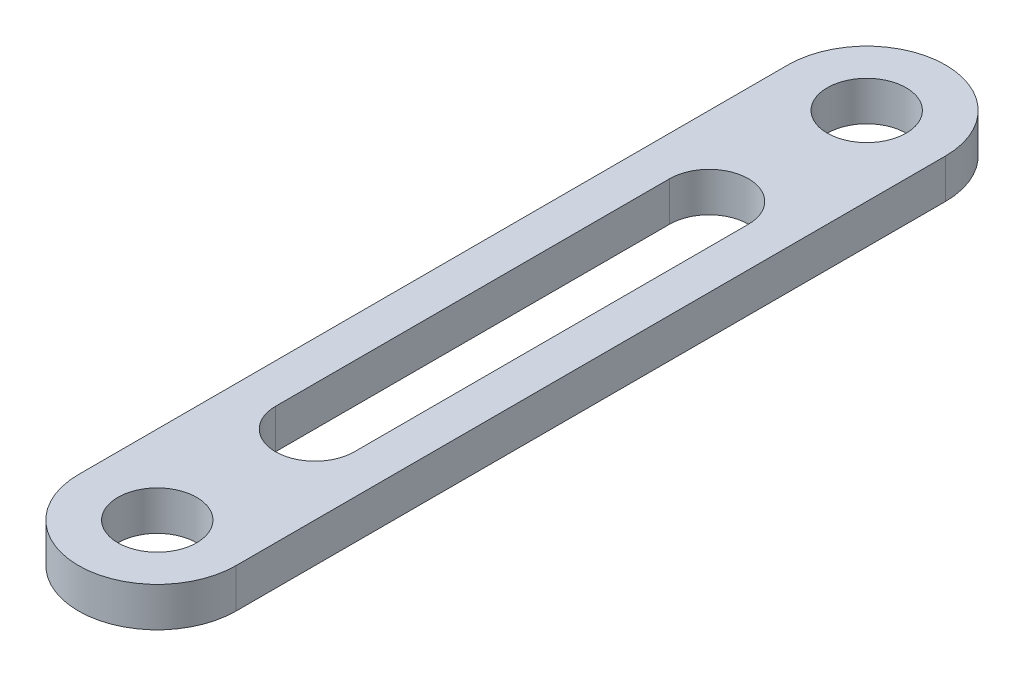
from build123d import *

# Parameters (mm, degrees)
SKETCH1_R           = 5
BOSS_EXTRUDE1_DEPTH = 5


with BuildPart() as part:
    # Sketch1 → Boss-Extrude1 (new body)
    with BuildSketch(Plane(origin=(0, 0, 0), x_dir=(1, 0, 0), z_dir=(0, 1, 0))):
        with BuildLine():
            Line((10, 0), (10, -90))
            ThreePointArc((10, -90), (0, -100), (-10, -90))
            Line((-10, -90), (-10, 0))
            ThreePointArc((-10, 0), (0, 10), (10, 0))
        make_face()
        Circle(SKETCH1_R, mode=Mode.SUBTRACT)
        with Locations((0, -90)):
            Circle(SKETCH1_R, mode=Mode.SUBTRACT)
        with BuildLine():
            Line((5, -20), (5, -70))
            ThreePointArc((5, -70), (0, -75), (-5, -70))
            Line((-5, -70), (-5, -20))
            ThreePointArc((-5, -20), (0, -15), (5, -20))
        make_face(mode=Mode.SUBTRACT)
    extrude(amount=BOSS_EXTRUDE1_DEPTH)


solid = part.part
